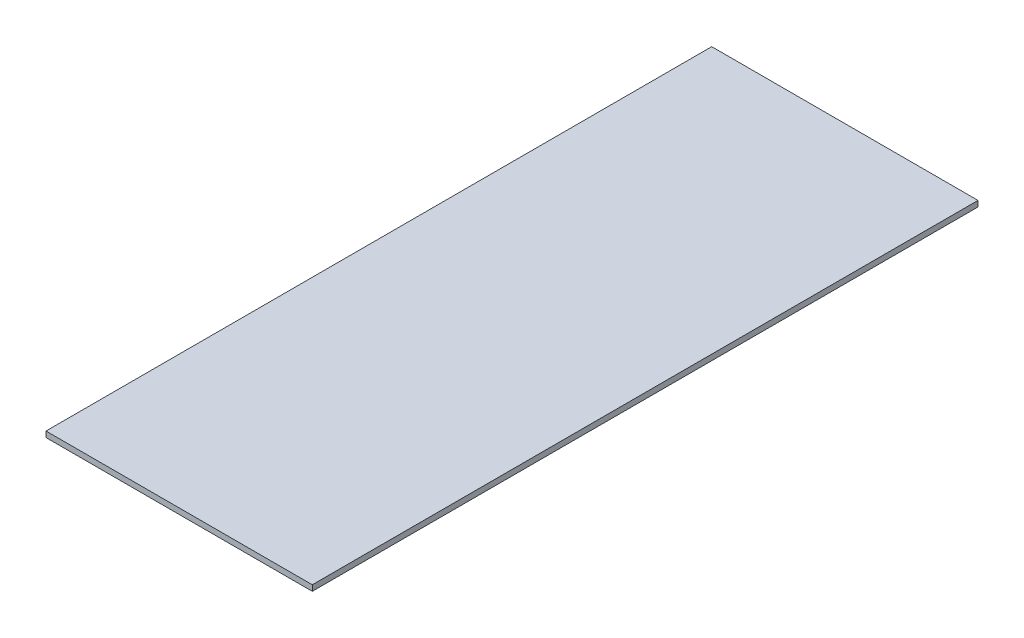
from build123d import *

# Parameters (mm, degrees)
SKETCH2_W           = 140
SKETCH2_H           = 350
BOSS_EXTRUDE1_DEPTH = 3


with BuildPart() as part:
    # Sketch2 → Boss-Extrude1 (new body)
    with BuildSketch(Plane(origin=(0, 0, 0), x_dir=(1, 0, 0), z_dir=(0, 1, 0))):
        with Locations((70, 175)):
            Rectangle(SKETCH2_W, SKETCH2_H)
    extrude(amount=BOSS_EXTRUDE1_DEPTH)


solid = part.part
